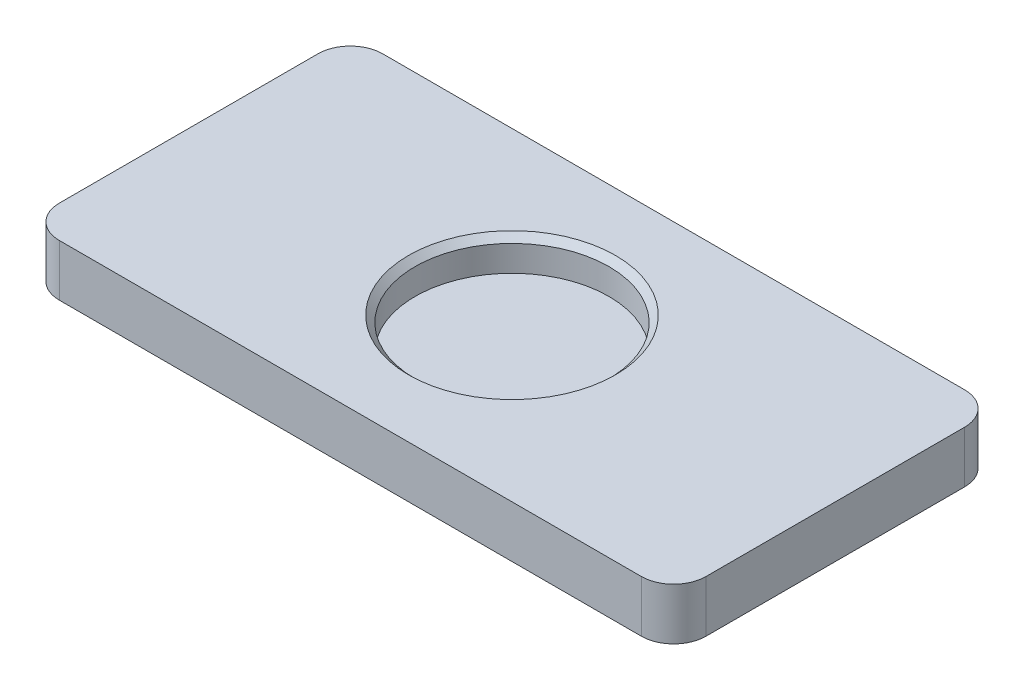
from build123d import *

# Parameters (mm, degrees)
SKETCH2_W           = 50
SKETCH2_H           = 25
BOSS_EXTRUDE1_DEPTH = 4
FILLET1_R           = 2.5
SKETCH3_R           = 7.5
CUT_EXTRUDE1_DEPTH  = 2.5
CHAMFER1_SIZE       = 0.5


with BuildPart() as part:
    # Sketch2 → Boss-Extrude1 (new body)
    with BuildSketch(Plane(origin=(0, 0, 0), x_dir=(1, 0, 0), z_dir=(0, 1, 0))):
        Rectangle(SKETCH2_W, SKETCH2_H)
    extrude(amount=BOSS_EXTRUDE1_DEPTH)

    # Fillet1
    fillet1_edges = [part.edges().sort_by_distance(p)[0] for p in [
        (25, 2, 12.5),
        (-25, 2, 12.5),
        (-25, 2, -12.5),
        (25, 2, -12.5),
    ]]
    fillet(fillet1_edges, radius=FILLET1_R)

    # Sketch3 → Cut-Extrude1 (cut)
    with BuildSketch(Plane(origin=(0, 4, 0), x_dir=(1, 0, 0), z_dir=(0, 1, 0))):
        Circle(SKETCH3_R)
    extrude(amount=-CUT_EXTRUDE1_DEPTH, mode=Mode.SUBTRACT)

    # Chamfer1
    chamfer1_edges = [part.edges().sort_by_distance(p)[0] for p in [
        (-7.5, 4, 0),
    ]]
    chamfer(chamfer1_edges, length=CHAMFER1_SIZE)


solid = part.part
